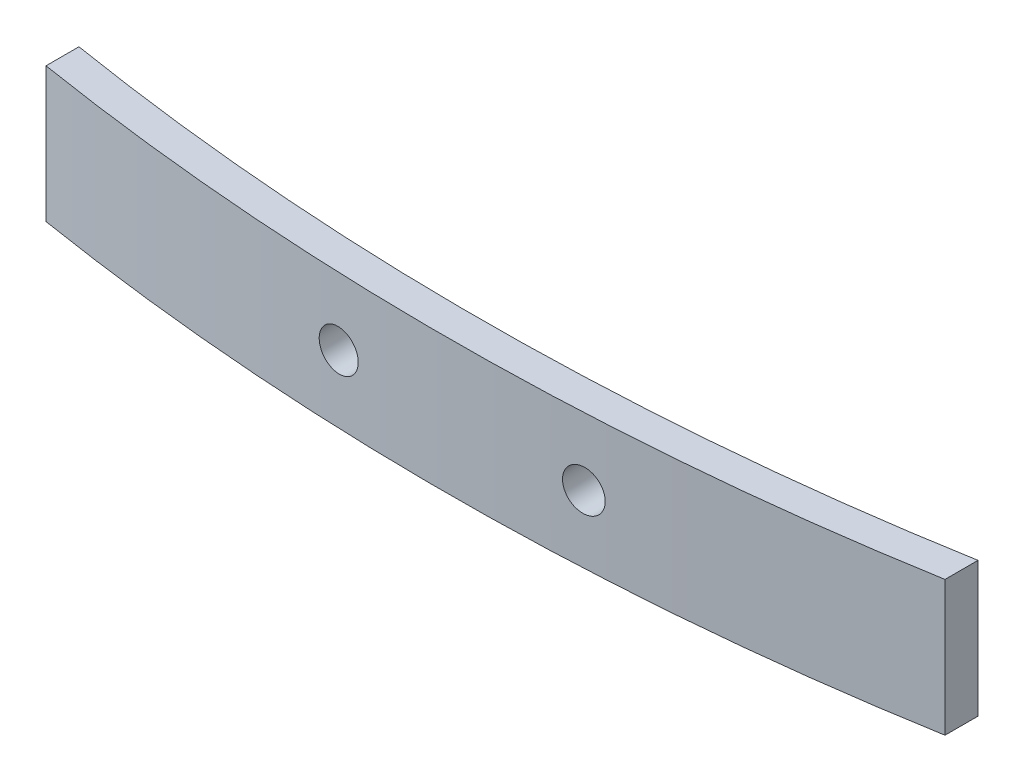
from build123d import *

# Parameters (mm, degrees)
BOSS_EXTRUDE1_DEPTH     = 8.3
SKETCH2_R               = 1.25
CUT_EXTRUDE1_DEPTH      = 3.700074126
CUT_EXTRUDE1_DEPTH_BACK = 2.753123062


with BuildPart() as part:
    # Sketch1 → Boss-Extrude1 (new body)
    with BuildSketch(Plane(origin=(0, 0, 0), x_dir=(1, 0, 0), z_dir=(0, 1, 0))):
        with BuildLine():
            Line((27.5, 1.753123062), (27.5, -0.276653737))
            ThreePointArc((27.5, -0.276653737), (0.011940827, -2.697774775), (-27.5, -0.56509193))
            Line((-27.5, -0.56509193), (-27.5, 1.461094109))
            ThreePointArc((-27.5, 1.461094109), (0.012237892, -0.697745363), (27.5, 1.753123062))
        make_face()
    extrude(amount=BOSS_EXTRUDE1_DEPTH)

    # Sketch2 → Cut-Extrude1 (cut, two sides)
    with BuildSketch(Plane.XY) as cut_extrude1_sk:
        with Locations((7.5, 4.15)):
            Circle(SKETCH2_R)
        with Locations((-7.5, 4.15)):
            Circle(SKETCH2_R)
    extrude(amount=CUT_EXTRUDE1_DEPTH, mode=Mode.SUBTRACT)
    extrude(cut_extrude1_sk.sketch, amount=-CUT_EXTRUDE1_DEPTH_BACK, mode=Mode.SUBTRACT)


solid = part.part
